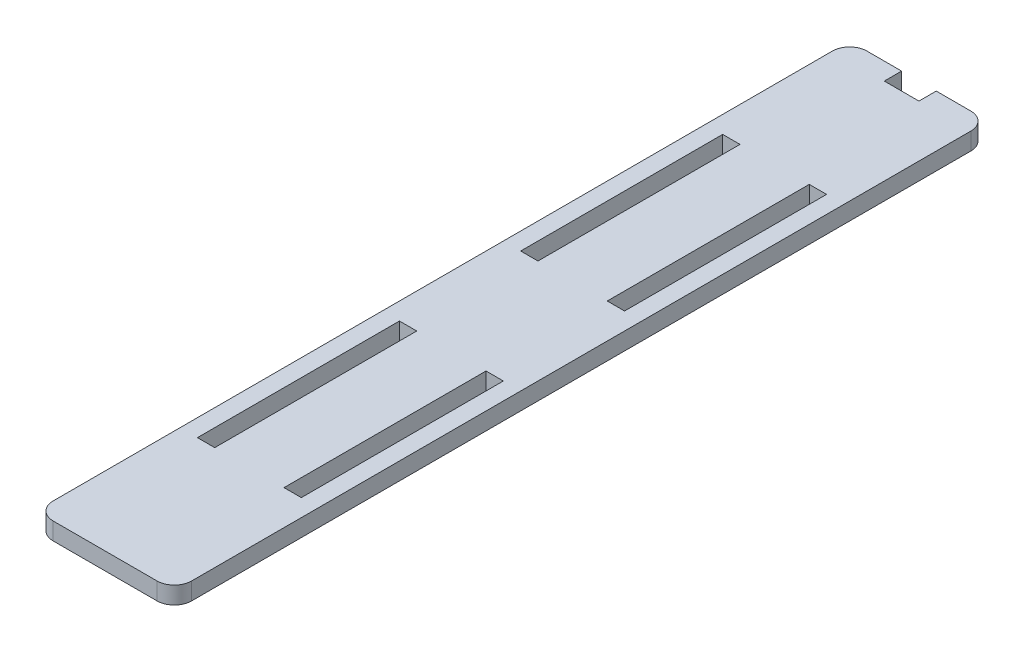
from build123d import *

# Parameters (mm, degrees)
SKETCH1_W               = 24
SKETCH1_H               = 141
BOSS_EXTRUDE1_DEPTH     = 1.5
SKETCH2_W               = 3
SKETCH2_H               = 35
CUT_EXTRUDE1_DEPTH      = 2.5
CUT_EXTRUDE1_DEPTH_BACK = 2.5
FILLET1_R               = 3
SKETCH3_W               = 6
SKETCH3_H               = 3
CUT_EXTRUDE2_DEPTH      = 2.5
CUT_EXTRUDE2_DEPTH_BACK = 2.5


with BuildPart() as part:
    # Sketch1 → Boss-Extrude1 (new body, symmetric)
    with BuildSketch(Plane(origin=(0, 0, 0), x_dir=(1, 0, 0), z_dir=(0, 1, 0))):
        Rectangle(SKETCH1_W, SKETCH1_H)
    extrude(amount=BOSS_EXTRUDE1_DEPTH, both=True)

    # Sketch2 → Cut-Extrude1 (cut, two sides)
    with BuildSketch(Plane(origin=(0, 0, 0), x_dir=(1, 0, 0), z_dir=(0, 1, 0))) as cut_extrude1_sk:
        with Locations((-7.5, 28)):
            Rectangle(SKETCH2_W, SKETCH2_H)
        with Locations((7.5, 28)):
            Rectangle(SKETCH2_W, SKETCH2_H)
        with Locations((7.5, -28)):
            Rectangle(SKETCH2_W, SKETCH2_H)
        with Locations((-7.5, -28)):
            Rectangle(SKETCH2_W, SKETCH2_H)
    extrude(amount=CUT_EXTRUDE1_DEPTH, mode=Mode.SUBTRACT)
    extrude(cut_extrude1_sk.sketch, amount=-CUT_EXTRUDE1_DEPTH_BACK, mode=Mode.SUBTRACT)

    # Fillet1
    fillet1_edges = [part.edges().sort_by_distance(p)[0] for p in [
        (-12, 0, -70.5),
        (12, 0, -70.5),
        (12, 0, 70.5),
        (-12, 0, 70.5),
    ]]
    fillet(fillet1_edges, radius=FILLET1_R)

    # Sketch3 → Cut-Extrude2 (cut, two sides)
    with BuildSketch(Plane(origin=(0, 0, 0), x_dir=(1, 0, 0), z_dir=(0, 1, 0))) as cut_extrude2_sk:
        with Locations((0, 69)):
            Rectangle(SKETCH3_W, SKETCH3_H)
    extrude(amount=CUT_EXTRUDE2_DEPTH, mode=Mode.SUBTRACT)
    extrude(cut_extrude2_sk.sketch, amount=-CUT_EXTRUDE2_DEPTH_BACK, mode=Mode.SUBTRACT)


solid = part.part
